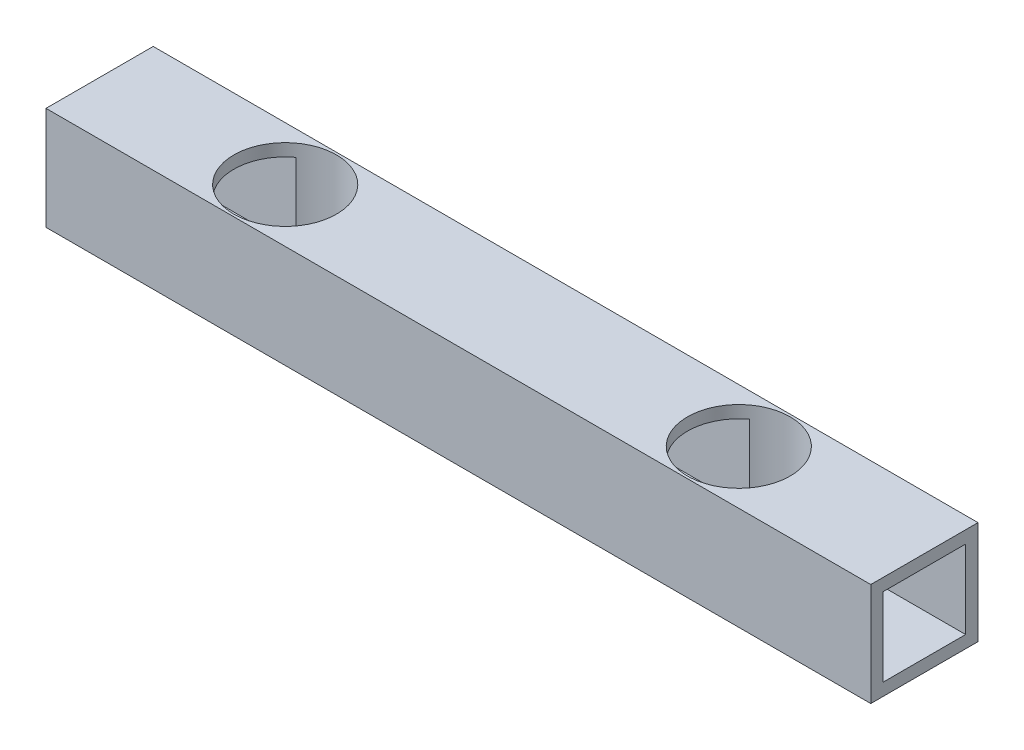
from build123d import *

# Parameters (mm, degrees)
SKETCH1_W           = 200
SKETCH1_H           = 26
BOSS_EXTRUDE1_DEPTH = 25
SHELL1_T            = -3
SKETCH2_R           = 12.45
CUT_EXTRUDE1_DEPTH  = 25


with BuildPart() as part:
    # Sketch1 → Boss-Extrude1 (new body)
    with BuildSketch(Plane(origin=(0, 0, 0), x_dir=(1, 0, 0), z_dir=(0, 1, 0))):
        Rectangle(SKETCH1_W, SKETCH1_H)
    extrude(amount=BOSS_EXTRUDE1_DEPTH)

    # Shell1
    shell1_openings = [part.faces().sort_by_distance(p)[0] for p in [
        (100, 12.5, 0),
        (-100, 12.5, 0),
    ]]
    offset(amount=SHELL1_T, openings=shell1_openings, kind=Kind.INTERSECTION)

    # Sketch2 → Cut-Extrude1 (cut)
    with BuildSketch(Plane(origin=(0, 25, 0), x_dir=(1, 0, 0), z_dir=(0, 1, 0))):
        with Locations((-55, 0)):
            Circle(SKETCH2_R)
        with Locations((55, 0)):
            Circle(SKETCH2_R)
    extrude(amount=-CUT_EXTRUDE1_DEPTH, mode=Mode.SUBTRACT)


solid = part.part
